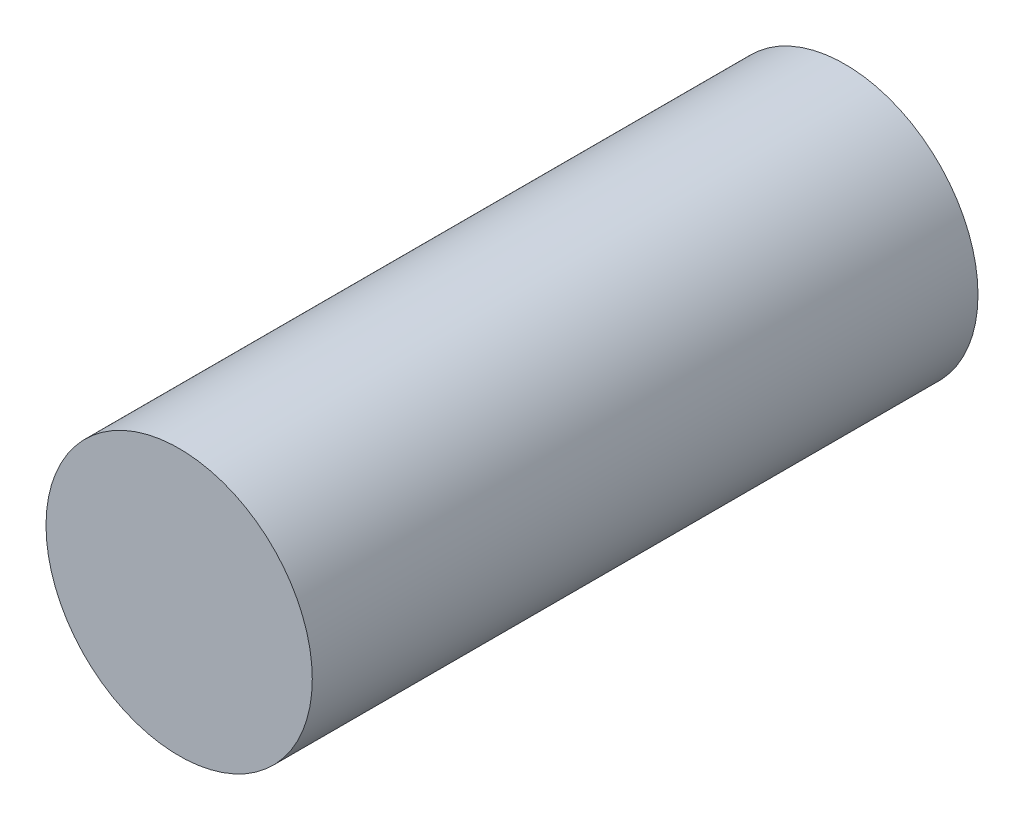
from build123d import *

# Parameters (mm, degrees)
ESQUISSE1_R             = 4
BOSS_EXTRU_1_DEPTH      = 20
ESQUISSE2_R             = 1.75
ENL_V_MAT_EXTRU_1_DEPTH = 10
ESQUISSE3_R             = 2
ENL_V_MAT_EXTRU_2_DEPTH = 5


with BuildPart() as part:
    # Esquisse1 → Boss.-Extru.1 (new body)
    with BuildSketch(Plane.XY):
        Circle(ESQUISSE1_R)
    extrude(amount=BOSS_EXTRU_1_DEPTH)

    # Esquisse2 → Enlèv. mat.-Extru.1 (cut)
    with BuildSketch(Plane(origin=(0, 0, 0), x_dir=(-1, 0, 0), z_dir=(0, 0, -1))):
        Circle(ESQUISSE2_R)
    extrude(amount=-ENL_V_MAT_EXTRU_1_DEPTH, mode=Mode.SUBTRACT)

    # Esquisse3 → Enlèv. mat.-Extru.2 (cut)
    with BuildSketch(Plane(origin=(0, 0, 0), x_dir=(-1, 0, 0), z_dir=(0, 0, -1))):
        Circle(ESQUISSE3_R)
    extrude(amount=-ENL_V_MAT_EXTRU_2_DEPTH, mode=Mode.SUBTRACT)


solid = part.part
